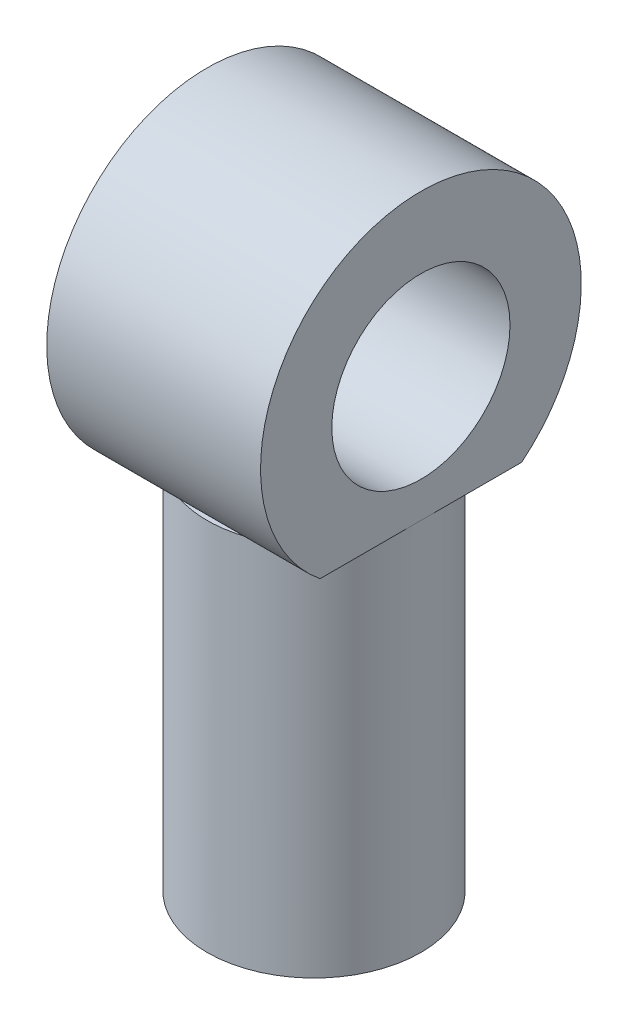
from build123d import *

# Parameters (mm, degrees)
SKETCH1_R                 = 3
CRANK_BODY_DEPTH          = 10
SKETCH2_R                 = 1.55
DOWEL_SHAFT_DEPTH         = 9
PIN_SHAFT_BODY_DEPTH      = 3
PIN_SHAFT_BODY_DEPTH_BACK = 3
SKETCH4_R                 = 2.5
PIN_SHAFT_DEPTH           = 20.962464778
SKETCH1_2_OUTSIDE_W       = 12.286
SKETCH1_2_OUTSIDE_H       = 15.286
SKETCH1_2_OUTSIDE_R       = 3
SMOOTHING_CUTS_DEPTH      = 10.5


with BuildPart() as part:
    # Sketch1 → crank_body (new body)
    with BuildSketch(Plane(origin=(0, 0, 0), x_dir=(1, 0, 0), z_dir=(0, 1, 0))):
        Circle(SKETCH1_R)
    extrude(amount=CRANK_BODY_DEPTH)

    # Sketch2 → dowel_shaft (cut)
    with BuildSketch(Plane.XZ):
        Circle(SKETCH2_R)
    extrude(amount=-DOWEL_SHAFT_DEPTH, mode=Mode.SUBTRACT)

    # Sketch3 → pin_shaft_body (add, two sides: drawn at the far end of the back side and taken through both)
    with BuildSketch(Plane(origin=(0, 0, 0), x_dir=(0, 0, -1), z_dir=(1, 0, 0)).offset(-PIN_SHAFT_BODY_DEPTH_BACK)):
        with BuildLine():
            Line((-3, 10.5), (-3, 10))
            Line((-3, 10), (3, 10))
            Line((3, 10), (3, 10.5))
            Line((3, 10.5), (2.828427125, 10.5))
            ThreePointArc((2.828427125, 10.5), (0, 18.5), (-2.828427125, 10.5))
            Line((-2.828427125, 10.5), (-3, 10.5))
        make_face()
    extrude(amount=PIN_SHAFT_BODY_DEPTH + PIN_SHAFT_BODY_DEPTH_BACK)

    # Sketch4 → pin_shaft (cut, through all)
    with BuildSketch(Plane(origin=(3, 0, 0), x_dir=(0, 0, -1), z_dir=(1, 0, 0))):
        with Locations((0, 14)):
            Circle(SKETCH4_R)
    extrude(amount=-PIN_SHAFT_DEPTH, mode=Mode.SUBTRACT)

    # Sketch1_2 outside → smoothing_cuts (cut)
    with BuildSketch(Plane(origin=(0, 0, 0), x_dir=(1, 0, 0), z_dir=(0, 1, 0))):
        Rectangle(SKETCH1_2_OUTSIDE_W, SKETCH1_2_OUTSIDE_H)
        Circle(SKETCH1_2_OUTSIDE_R, mode=Mode.SUBTRACT)
    extrude(amount=SMOOTHING_CUTS_DEPTH, mode=Mode.SUBTRACT)


solid = part.part
